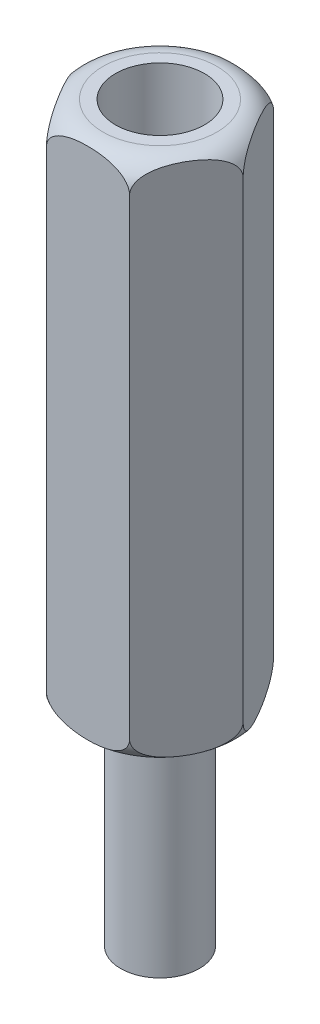
from build123d import *

# Parameters (mm, degrees)
BOSS_EXTRUDE1_DEPTH      = 20
M3_CLEARANCE_HOLE1_D     = 3.4
M3_CLEARANCE_HOLE1_DEPTH = 12
M3_CLEARANCE_HOLE1_TIP   = 1.021463052
SKETCH5_R                = 1.5
BOSS_EXTRUDE2_DEPTH      = 8


with BuildPart() as part:
    # Sketch1 → Boss-Extrude1 (new body)
    with BuildSketch(Plane(origin=(0, 0, 0), x_dir=(1, 0, 0), z_dir=(0, 1, 0))):
        Polygon((3.175426481, 0), (1.58771324, 2.75), (-1.58771324, 2.75), (-3.175426481, 0), (-1.58771324, -2.75), (1.58771324, -2.75), align=None)
    extrude(amount=BOSS_EXTRUDE1_DEPTH)

    # M3 Clearance Hole1
    with Locations(Plane(origin=(0, 20, 0), x_dir=(-1, 0, 0), z_dir=(0, 1, 0))):
        with Locations((0, 0)):
            Hole(M3_CLEARANCE_HOLE1_D / 2, depth=M3_CLEARANCE_HOLE1_DEPTH)
            with Locations((0, 0, -(M3_CLEARANCE_HOLE1_DEPTH + M3_CLEARANCE_HOLE1_TIP / 2))):  # 118° drill point
                Cone(0, M3_CLEARANCE_HOLE1_D / 2, M3_CLEARANCE_HOLE1_TIP, mode=Mode.SUBTRACT)

    # Sketch4 → Cut-Revolve1 (revolve, cut)
    with BuildSketch(Plane.XY):
        with BuildLine():
            Line((-2.175426481, 20), (-3.175426481, 20))
            Line((-3.175426481, 20), (-3.175426481, 19))
            ThreePointArc((-3.175426481, 19), (-2.882533262, 19.707106781), (-2.175426481, 20))
        make_face()
        with BuildLine():
            Line((-3.175426481, 1), (-3.175426481, 0))
            Line((-3.175426481, 0), (-2.175426481, 0))
            ThreePointArc((-2.175426481, 0), (-2.882533262, 0.292893219), (-3.175426481, 1))
        make_face()
    revolve(axis=Axis((0, 20, 0), (0, -1, 0)), mode=Mode.SUBTRACT)

    # Sketch5 → Boss-Extrude2 (add)
    with BuildSketch(Plane.XZ):
        Circle(SKETCH5_R)
    extrude(amount=BOSS_EXTRUDE2_DEPTH)


solid = part.part
